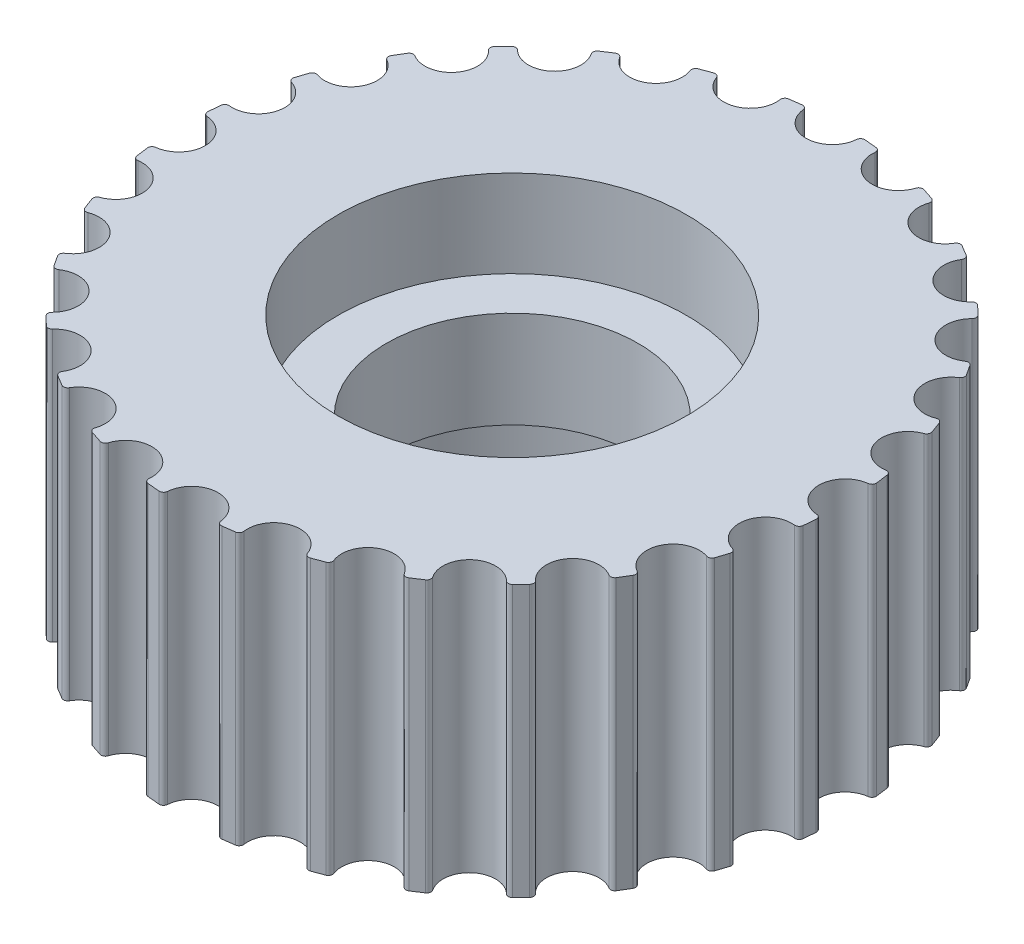
from build123d import *

# Parameters (mm, degrees)
SKETCH1_R           = 6.25
BOSS_EXTRUDE1_DEPTH = 3.5
SKETCH2_R           = 6.25
SKETCH2_R_2         = 3.25
BOSS_EXTRUDE2_DEPTH = 1.25
SKETCH2_3_R         = 6.25
SKETCH2_3_R_2       = 4.5
BOSS_EXTRUDE3_DEPTH = 3.5


with BuildPart() as part:
    # Sketch1 → Boss-Extrude1 (new, symmetric)
    with BuildSketch(Plane(origin=(0, 0, 0), x_dir=(1, 0, 0), z_dir=(0, 1, 0))):
        with BuildLine():
            Line((-1.272883518, 8.404151804), (-0.962236216, 8.445359759))
            ThreePointArc((-0.962236216, 8.445359759), (-0.881465475, 8.422279476), (-0.840537342, 8.348920768))
            ThreePointArc((-0.840537342, 8.348920768), (-0.151870509, 7.748511815), (0.512740469, 8.375444957))
            ThreePointArc((0.512740469, 8.375444957), (0.550762618, 8.450351087), (0.630566928, 8.476578635))
            Line((0.630566928, 8.476578635), (0.942595286, 8.447627892))
            ThreePointArc((0.942595286, 8.447627892), (1.01620509, 8.407153099), (1.039783222, 8.326526281))
            ThreePointArc((1.039783222, 8.326526281), (1.577580178, 7.587928047), (2.36503372, 8.05125281))
            ThreePointArc((2.36503372, 8.05125281), (2.418770756, 8.115820163), (2.502410384, 8.123632002))
            Line((2.502410384, 8.123632002), (2.800173393, 8.025974274))
            ThreePointArc((2.800173393, 8.025974274), (2.862931157, 7.970134546), (2.867976981, 7.886282582))
            ThreePointArc((2.867976981, 7.886282582), (3.227936675, 7.046531467), (4.098746572, 7.323014814))
            ThreePointArc((4.098746572, 7.323014814), (4.165503896, 7.374005713), (4.248784801, 7.363010125))
            Line((4.248784801, 7.363010125), (4.517351382, 7.201542376))
            ThreePointArc((4.517351382, 7.201542376), (4.566110168, 7.133137751), (4.552370666, 7.05026533))
            ThreePointArc((4.552370666, 7.05026533), (4.716443217, 6.151469961), (5.626943424, 6.227247861))
            ThreePointArc((5.626943424, 6.227247861), (5.703373545, 6.26210541), (5.782119676, 6.232853759))
            Line((5.782119676, 6.232853759), (6.008022777, 6.015672658))
            ThreePointArc((6.008022777, 6.015672658), (6.040337618, 5.938133228), (6.008501745, 5.860395919))
            ThreePointArc((6.008501745, 5.860395919), (5.96845987, 4.947625649), (6.872994105, 4.818898283))
            ThreePointArc((6.872994105, 4.818898283), (6.955264498, 4.835874578), (7.025527194, 4.789833665))
            Line((7.025527194, 4.789833665), (7.197439091, 4.527829579))
            ThreePointArc((7.197439091, 4.527829579), (7.211689585, 4.445043496), (7.163353725, 4.376339371))
            ThreePointArc((7.163353725, 4.376339371), (6.921205291, 3.495364313), (7.77441643, 3.168586608))
            ThreePointArc((7.77441643, 3.168586608), (7.858401713, 3.166830387), (7.91665771, 3.106308895))
            Line((7.91665771, 3.106308895), (8.025958023, 2.812619802))
            ThreePointArc((8.025958023, 2.812619802), (8.021429591, 2.728738306), (7.959017506, 2.672512478))
            ThreePointArc((7.959017506, 2.672512478), (7.526904846, 1.8675084), (8.28600932, 1.359066354))
            ThreePointArc((8.28600932, 1.359066354), (8.367498121, 1.338665682), (8.41082622, 1.266698411))
            Line((8.41082622, 1.266698411), (8.452034175, 0.95605111))
            ThreePointArc((8.452034175, 0.95605111), (8.428953891, 0.875280368), (8.355595183, 0.834352235))
            ThreePointArc((8.355595183, 0.834352235), (7.75518623, 0.145685402), (8.382119372, -0.518925576))
            ThreePointArc((8.382119372, -0.518925576), (8.457025502, -0.556947725), (8.48325305, -0.636752035))
            Line((8.48325305, -0.636752035), (8.454302308, -0.948780393))
            ThreePointArc((8.454302308, -0.948780393), (8.413827514, -1.022390197), (8.333200696, -1.045968329))
            ThreePointArc((8.333200696, -1.045968329), (7.594602462, -1.583765285), (8.057927226, -2.371218827))
            ThreePointArc((8.057927226, -2.371218827), (8.122494578, -2.424955863), (8.130306417, -2.50859549))
            Line((8.130306417, -2.50859549), (8.032648689, -2.8063585))
            ThreePointArc((8.032648689, -2.8063585), (7.976808961, -2.869116263), (7.892956997, -2.874162087))
            ThreePointArc((7.892956997, -2.874162087), (7.053205883, -3.234121782), (7.329689229, -4.104931679))
            ThreePointArc((7.329689229, -4.104931679), (7.380680128, -4.171689003), (7.36968454, -4.254969908))
            Line((7.36968454, -4.254969908), (7.208216792, -4.523536489))
            ThreePointArc((7.208216792, -4.523536489), (7.139812166, -4.572295275), (7.056939745, -4.558555773))
            ThreePointArc((7.056939745, -4.558555773), (6.158144376, -4.722628324), (6.233922277, -5.633128531))
            ThreePointArc((6.233922277, -5.633128531), (6.268779825, -5.709558652), (6.239528174, -5.788304783))
            Line((6.239528174, -5.788304783), (6.022347074, -6.014207884))
            ThreePointArc((6.022347074, -6.014207884), (5.944807644, -6.046522725), (5.867070334, -6.014686852))
            ThreePointArc((5.867070334, -6.014686852), (4.954300065, -5.974644977), (4.825572698, -6.879179212))
            ThreePointArc((4.825572698, -6.879179212), (4.842548993, -6.961449605), (4.79650808, -7.0317123))
            Line((4.79650808, -7.0317123), (4.534503994, -7.203624198))
            ThreePointArc((4.534503994, -7.203624198), (4.451717911, -7.217874692), (4.383013786, -7.169538832))
            ThreePointArc((4.383013786, -7.169538832), (3.502038728, -6.927390398), (3.175261023, -7.780601537))
            ThreePointArc((3.175261023, -7.780601537), (3.173504802, -7.86458682), (3.11298331, -7.922842817))
            Line((3.11298331, -7.922842817), (2.819294218, -8.03214313))
            ThreePointArc((2.819294218, -8.03214313), (2.735412721, -8.027614698), (2.679186893, -7.965202613))
            ThreePointArc((2.679186893, -7.965202613), (1.874182815, -7.533089953), (1.36574077, -8.292194427))
            ThreePointArc((1.36574077, -8.292194427), (1.345340097, -8.373683228), (1.273372827, -8.417011326))
            Line((1.273372827, -8.417011326), (0.962725525, -8.458219281))
            ThreePointArc((0.962725525, -8.458219281), (0.881954784, -8.435138998), (0.84102665, -8.36178029))
            ThreePointArc((0.84102665, -8.36178029), (0.152359818, -7.761371337), (-0.512251161, -8.388304479))
            ThreePointArc((-0.512251161, -8.388304479), (-0.55027331, -8.463210609), (-0.63007762, -8.489438157))
            Line((-0.63007762, -8.489438157), (-0.942105978, -8.460487415))
            ThreePointArc((-0.942105978, -8.460487415), (-1.015715781, -8.420012621), (-1.039293913, -8.339385803))
            ThreePointArc((-1.039293913, -8.339385803), (-1.577090869, -7.600787569), (-2.364544411, -8.064112332))
            ThreePointArc((-2.364544411, -8.064112332), (-2.418281448, -8.128679685), (-2.501921075, -8.136491524))
            Line((-2.501921075, -8.136491524), (-2.799684085, -8.038833796))
            ThreePointArc((-2.799684085, -8.038833796), (-2.862441848, -7.982994068), (-2.867487672, -7.899142104))
            ThreePointArc((-2.867487672, -7.899142104), (-3.227447367, -7.059390989), (-4.098257263, -7.335874336))
            ThreePointArc((-4.098257263, -7.335874336), (-4.165014588, -7.386865235), (-4.248295493, -7.375869647))
            Line((-4.248295493, -7.375869647), (-4.516862073, -7.214401899))
            ThreePointArc((-4.516862073, -7.214401899), (-4.56562086, -7.145997273), (-4.551881357, -7.063124852))
            ThreePointArc((-4.551881357, -7.063124852), (-4.715953909, -6.164329483), (-5.626454116, -6.240107383))
            ThreePointArc((-5.626454116, -6.240107383), (-5.702884237, -6.274964932), (-5.781630367, -6.245713281))
            Line((-5.781630367, -6.245713281), (-6.007533469, -6.02853218))
            ThreePointArc((-6.007533469, -6.02853218), (-6.03984831, -5.950992751), (-6.008012437, -5.873255441))
            ThreePointArc((-6.008012437, -5.873255441), (-5.967970562, -4.960485171), (-6.872504796, -4.831757805))
            ThreePointArc((-6.872504796, -4.831757805), (-6.954775189, -4.8487341), (-7.025037885, -4.802693187))
            Line((-7.025037885, -4.802693187), (-7.196949783, -4.540689101))
            ThreePointArc((-7.196949783, -4.540689101), (-7.211200277, -4.457903018), (-7.162864417, -4.389198893))
            ThreePointArc((-7.162864417, -4.389198893), (-6.920715982, -3.508223835), (-7.773927122, -3.18144613))
            ThreePointArc((-7.773927122, -3.18144613), (-7.857912405, -3.179689909), (-7.916168401, -3.119168417))
            Line((-7.916168401, -3.119168417), (-8.025468715, -2.825479324))
            ThreePointArc((-8.025468715, -2.825479324), (-8.020940283, -2.741597828), (-7.958528198, -2.685372))
            ThreePointArc((-7.958528198, -2.685372), (-7.526415537, -1.880367922), (-8.285520012, -1.371925877))
            ThreePointArc((-8.285520012, -1.371925877), (-8.367008813, -1.351525204), (-8.410336911, -1.279557934))
            Line((-8.410336911, -1.279557934), (-8.451544866, -0.968910632))
            ThreePointArc((-8.451544866, -0.968910632), (-8.428464582, -0.888139891), (-8.355105875, -0.847211757))
            ThreePointArc((-8.355105875, -0.847211757), (-7.754696922, -0.158544924), (-8.381630064, 0.506066054))
            ThreePointArc((-8.381630064, 0.506066054), (-8.456536193, 0.544088203), (-8.482763741, 0.623892513))
            Line((-8.482763741, 0.623892513), (-8.453812999, 0.935920871))
            ThreePointArc((-8.453812999, 0.935920871), (-8.413338206, 1.009530675), (-8.332711388, 1.033108806))
            ThreePointArc((-8.332711388, 1.033108806), (-7.594113154, 1.570905763), (-8.057437917, 2.358359304))
            ThreePointArc((-8.057437917, 2.358359304), (-8.12200527, 2.412096341), (-8.129817109, 2.495735968))
            Line((-8.129817109, 2.495735968), (-8.032159381, 2.793498978))
            ThreePointArc((-8.032159381, 2.793498978), (-7.976319652, 2.856256741), (-7.892467689, 2.861302565))
            ThreePointArc((-7.892467689, 2.861302565), (-7.052716574, 3.22126226), (-7.329199921, 4.092072157))
            ThreePointArc((-7.329199921, 4.092072157), (-7.380190819, 4.158829481), (-7.369195231, 4.242110386))
            Line((-7.369195231, 4.242110386), (-7.207727483, 4.510676966))
            ThreePointArc((-7.207727483, 4.510676966), (-7.139322857, 4.559435753), (-7.056450436, 4.545696251))
            ThreePointArc((-7.056450436, 4.545696251), (-6.157655068, 4.709768802), (-6.233432968, 5.620269009))
            ThreePointArc((-6.233432968, 5.620269009), (-6.268290516, 5.69669913), (-6.239038866, 5.775445261))
            Line((-6.239038866, 5.775445261), (-6.021857765, 6.001348362))
            ThreePointArc((-6.021857765, 6.001348362), (-5.944318335, 6.033663203), (-5.866581026, 6.00182733))
            ThreePointArc((-5.866581026, 6.00182733), (-4.953810756, 5.961785455), (-4.82508339, 6.86631969))
            ThreePointArc((-4.82508339, 6.86631969), (-4.842059685, 6.948590082), (-4.796018772, 7.018852778))
            Line((-4.796018772, 7.018852778), (-4.534014685, 7.190764676))
            ThreePointArc((-4.534014685, 7.190764676), (-4.451228602, 7.20501517), (-4.382524478, 7.15667931))
            ThreePointArc((-4.382524478, 7.15667931), (-3.50154942, 6.914530876), (-3.174771715, 7.767742015))
            ThreePointArc((-3.174771715, 7.767742015), (-3.173015494, 7.851727298), (-3.112494002, 7.909983295))
            Line((-3.112494002, 7.909983295), (-2.818804909, 8.019283608))
            ThreePointArc((-2.818804909, 8.019283608), (-2.734923413, 8.014755176), (-2.678697585, 7.952343091))
            ThreePointArc((-2.678697585, 7.952343091), (-1.873693507, 7.520230431), (-1.365251461, 8.279334905))
            ThreePointArc((-1.365251461, 8.279334905), (-1.344850789, 8.360823706), (-1.272883518, 8.404151804))
        make_face()
        Circle(SKETCH1_R, mode=Mode.SUBTRACT)
    extrude(amount=BOSS_EXTRUDE1_DEPTH, both=True)

    # Sketch2 → Boss-Extrude2 (add, symmetric)
    with BuildSketch(Plane(origin=(0, 0, 0), x_dir=(1, 0, 0), z_dir=(0, 1, 0))):
        Circle(SKETCH2_R)
        Circle(SKETCH2_R_2, mode=Mode.SUBTRACT)
    extrude(amount=BOSS_EXTRUDE2_DEPTH, both=True)

    # Sketch2_3 → Boss-Extrude3 (add, symmetric)
    with BuildSketch(Plane(origin=(0, 0, 0), x_dir=(1, 0, 0), z_dir=(0, 1, 0))):
        Circle(SKETCH2_3_R)
        Circle(SKETCH2_3_R_2, mode=Mode.SUBTRACT)
    extrude(amount=BOSS_EXTRUDE3_DEPTH, both=True)


solid = part.part
